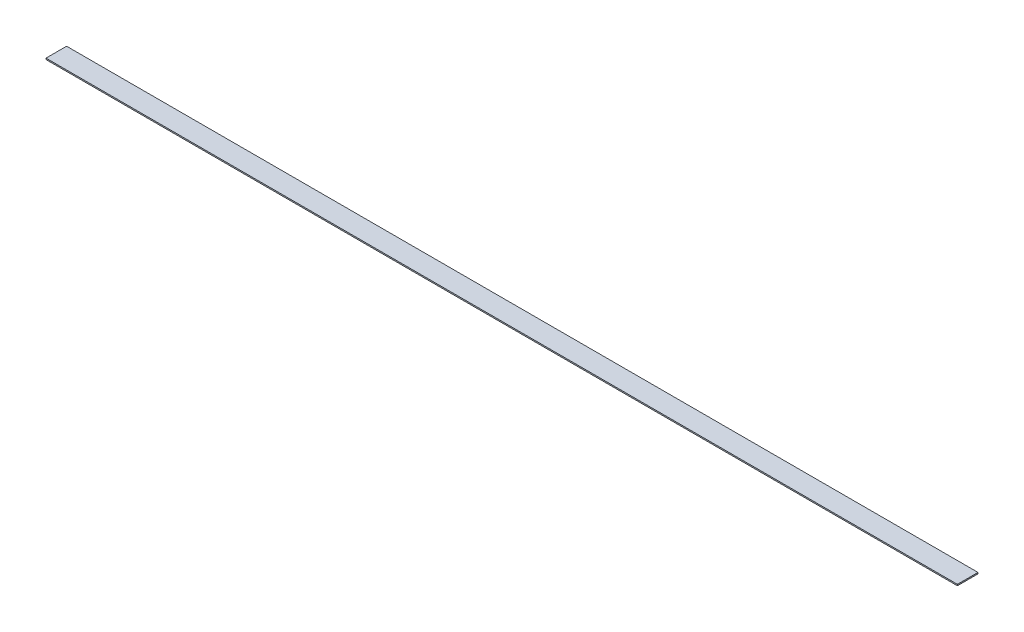
from build123d import *

# Parameters (mm, degrees)
SKETCH1_W           = 2247.9
SKETCH1_H           = 50.8
BOSS_EXTRUDE1_DEPTH = 3.175


with BuildPart() as part:
    # Sketch1 → Boss-Extrude1 (new body)
    with BuildSketch(Plane(origin=(0, 0, 0), x_dir=(1, 0, 0), z_dir=(0, 1, 0))):
        with Locations((1123.95, 25.4)):
            Rectangle(SKETCH1_W, SKETCH1_H)
    extrude(amount=BOSS_EXTRUDE1_DEPTH)


solid = part.part
